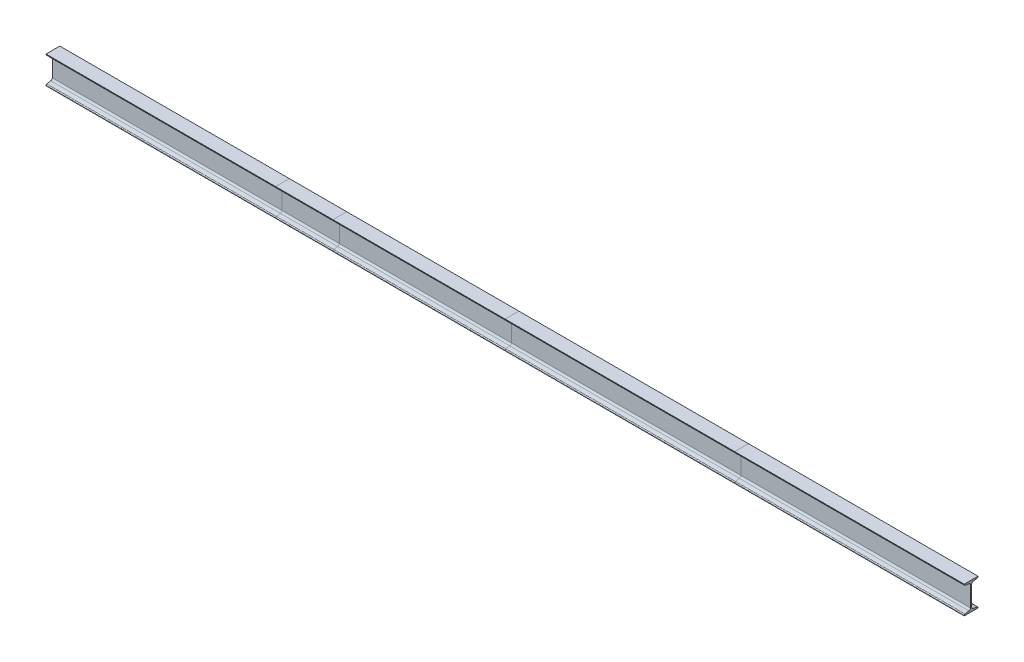
from build123d import *

# Parameters (mm, degrees)
SB_BEAM_120_X_12_1_DEPTH   = 1000
SB_BEAM_120_X_12_1_2_DEPTH = 250
SB_BEAM_120_X_12_1_3_DEPTH = 750
SB_BEAM_120_X_12_1_4_DEPTH = 1000
SB_BEAM_120_X_12_1_5_DEPTH = 1000


with BuildPart() as part:
    # Sketch11 → Sb beam 120 X 12(1) (new body)
    with BuildSketch(Plane(origin=(0, 0, 0), x_dir=(0, 0, 1), z_dir=(1, 0, 0))):
        with BuildLine():
            Line((-30, -60), (-30, -58.080070835))
            ThreePointArc((-30, -58.080070835), (-29.052095223, -55.494589303), (-26.657642624, -54.134502919))
            Line((-26.657642624, -54.134502919), (-9.184714752, -51.222135832))
            ThreePointArc((-9.184714752, -51.222135832), (-4.395809555, -48.501963064), (-2.5, -43.331))
            Line((-2.5, -43.331), (-2.5, 43.331))
            ThreePointArc((-2.5, 43.331), (-4.395809555, 48.501963064), (-9.184714752, 51.222135832))
            Line((-9.184714752, 51.222135832), (-26.657642624, 54.134502919))
            ThreePointArc((-26.657642624, 54.134502919), (-29.052095223, 55.494589303), (-30, 58.080070835))
            Line((-30, 58.080070835), (-30, 60))
            Line((-30, 60), (30, 60))
            Line((30, 60), (30, 58.080070835))
            ThreePointArc((30, 58.080070835), (29.052095223, 55.494589303), (26.657642624, 54.134502919))
            Line((26.657642624, 54.134502919), (9.184714752, 51.222135832))
            ThreePointArc((9.184714752, 51.222135832), (4.395809555, 48.501963064), (2.5, 43.331))
            Line((2.5, 43.331), (2.5, -43.331))
            ThreePointArc((2.5, -43.331), (4.395809555, -48.501963064), (9.184714752, -51.222135832))
            Line((9.184714752, -51.222135832), (26.657642624, -54.134502919))
            ThreePointArc((26.657642624, -54.134502919), (29.052095223, -55.494589303), (30, -58.080070835))
            Line((30, -58.080070835), (30, -60))
            Line((30, -60), (-30, -60))
        make_face()
    extrude(amount=SB_BEAM_120_X_12_1_DEPTH)


with BuildPart() as body_2:
    # Sketch11 on segment 2 (carried to segment 2) → Sb beam 120 X 12_1 2 (new body)
    with BuildSketch(Plane(origin=(1000, 0, 0), x_dir=(0, 0, 1), z_dir=(1, 0, 0))):
        with BuildLine():
            Line((-30, -60), (-30, -58.080070835))
            ThreePointArc((-30, -58.080070835), (-29.052095223, -55.494589303), (-26.657642624, -54.134502919))
            Line((-26.657642624, -54.134502919), (-9.184714752, -51.222135832))
            ThreePointArc((-9.184714752, -51.222135832), (-4.395809555, -48.501963064), (-2.5, -43.331))
            Line((-2.5, -43.331), (-2.5, 43.331))
            ThreePointArc((-2.5, 43.331), (-4.395809555, 48.501963064), (-9.184714752, 51.222135832))
            Line((-9.184714752, 51.222135832), (-26.657642624, 54.134502919))
            ThreePointArc((-26.657642624, 54.134502919), (-29.052095223, 55.494589303), (-30, 58.080070835))
            Line((-30, 58.080070835), (-30, 60))
            Line((-30, 60), (30, 60))
            Line((30, 60), (30, 58.080070835))
            ThreePointArc((30, 58.080070835), (29.052095223, 55.494589303), (26.657642624, 54.134502919))
            Line((26.657642624, 54.134502919), (9.184714752, 51.222135832))
            ThreePointArc((9.184714752, 51.222135832), (4.395809555, 48.501963064), (2.5, 43.331))
            Line((2.5, 43.331), (2.5, -43.331))
            ThreePointArc((2.5, -43.331), (4.395809555, -48.501963064), (9.184714752, -51.222135832))
            Line((9.184714752, -51.222135832), (26.657642624, -54.134502919))
            ThreePointArc((26.657642624, -54.134502919), (29.052095223, -55.494589303), (30, -58.080070835))
            Line((30, -58.080070835), (30, -60))
            Line((30, -60), (-30, -60))
        make_face()
    extrude(amount=SB_BEAM_120_X_12_1_2_DEPTH)


with BuildPart() as body_3:
    # Sketch11 on segment 3 (carried to segment 3) → Sb beam 120 X 12_1 3 (new body)
    with BuildSketch(Plane(origin=(1250, 0, 0), x_dir=(0, 0, 1), z_dir=(1, 0, 0))):
        with BuildLine():
            Line((-30, -60), (-30, -58.080070835))
            ThreePointArc((-30, -58.080070835), (-29.052095223, -55.494589303), (-26.657642624, -54.134502919))
            Line((-26.657642624, -54.134502919), (-9.184714752, -51.222135832))
            ThreePointArc((-9.184714752, -51.222135832), (-4.395809555, -48.501963064), (-2.5, -43.331))
            Line((-2.5, -43.331), (-2.5, 43.331))
            ThreePointArc((-2.5, 43.331), (-4.395809555, 48.501963064), (-9.184714752, 51.222135832))
            Line((-9.184714752, 51.222135832), (-26.657642624, 54.134502919))
            ThreePointArc((-26.657642624, 54.134502919), (-29.052095223, 55.494589303), (-30, 58.080070835))
            Line((-30, 58.080070835), (-30, 60))
            Line((-30, 60), (30, 60))
            Line((30, 60), (30, 58.080070835))
            ThreePointArc((30, 58.080070835), (29.052095223, 55.494589303), (26.657642624, 54.134502919))
            Line((26.657642624, 54.134502919), (9.184714752, 51.222135832))
            ThreePointArc((9.184714752, 51.222135832), (4.395809555, 48.501963064), (2.5, 43.331))
            Line((2.5, 43.331), (2.5, -43.331))
            ThreePointArc((2.5, -43.331), (4.395809555, -48.501963064), (9.184714752, -51.222135832))
            Line((9.184714752, -51.222135832), (26.657642624, -54.134502919))
            ThreePointArc((26.657642624, -54.134502919), (29.052095223, -55.494589303), (30, -58.080070835))
            Line((30, -58.080070835), (30, -60))
            Line((30, -60), (-30, -60))
        make_face()
    extrude(amount=SB_BEAM_120_X_12_1_3_DEPTH)


with BuildPart() as body_4:
    # Sketch11 on segment 4 (carried to segment 4) → Sb beam 120 X 12_1 4 (new body)
    with BuildSketch(Plane(origin=(2000, 0, 0), x_dir=(0, 0, 1), z_dir=(1, 0, 0))):
        with BuildLine():
            Line((-30, -60), (-30, -58.080070835))
            ThreePointArc((-30, -58.080070835), (-29.052095223, -55.494589303), (-26.657642624, -54.134502919))
            Line((-26.657642624, -54.134502919), (-9.184714752, -51.222135832))
            ThreePointArc((-9.184714752, -51.222135832), (-4.395809555, -48.501963064), (-2.5, -43.331))
            Line((-2.5, -43.331), (-2.5, 43.331))
            ThreePointArc((-2.5, 43.331), (-4.395809555, 48.501963064), (-9.184714752, 51.222135832))
            Line((-9.184714752, 51.222135832), (-26.657642624, 54.134502919))
            ThreePointArc((-26.657642624, 54.134502919), (-29.052095223, 55.494589303), (-30, 58.080070835))
            Line((-30, 58.080070835), (-30, 60))
            Line((-30, 60), (30, 60))
            Line((30, 60), (30, 58.080070835))
            ThreePointArc((30, 58.080070835), (29.052095223, 55.494589303), (26.657642624, 54.134502919))
            Line((26.657642624, 54.134502919), (9.184714752, 51.222135832))
            ThreePointArc((9.184714752, 51.222135832), (4.395809555, 48.501963064), (2.5, 43.331))
            Line((2.5, 43.331), (2.5, -43.331))
            ThreePointArc((2.5, -43.331), (4.395809555, -48.501963064), (9.184714752, -51.222135832))
            Line((9.184714752, -51.222135832), (26.657642624, -54.134502919))
            ThreePointArc((26.657642624, -54.134502919), (29.052095223, -55.494589303), (30, -58.080070835))
            Line((30, -58.080070835), (30, -60))
            Line((30, -60), (-30, -60))
        make_face()
    extrude(amount=SB_BEAM_120_X_12_1_4_DEPTH)


with BuildPart() as body_5:
    # Sketch11 on segment 5 (carried to segment 5) → Sb beam 120 X 12_1 5 (new body)
    with BuildSketch(Plane(origin=(3000, 0, 0), x_dir=(0, 0, 1), z_dir=(1, 0, 0))):
        with BuildLine():
            Line((-30, -60), (-30, -58.080070835))
            ThreePointArc((-30, -58.080070835), (-29.052095223, -55.494589303), (-26.657642624, -54.134502919))
            Line((-26.657642624, -54.134502919), (-9.184714752, -51.222135832))
            ThreePointArc((-9.184714752, -51.222135832), (-4.395809555, -48.501963064), (-2.5, -43.331))
            Line((-2.5, -43.331), (-2.5, 43.331))
            ThreePointArc((-2.5, 43.331), (-4.395809555, 48.501963064), (-9.184714752, 51.222135832))
            Line((-9.184714752, 51.222135832), (-26.657642624, 54.134502919))
            ThreePointArc((-26.657642624, 54.134502919), (-29.052095223, 55.494589303), (-30, 58.080070835))
            Line((-30, 58.080070835), (-30, 60))
            Line((-30, 60), (30, 60))
            Line((30, 60), (30, 58.080070835))
            ThreePointArc((30, 58.080070835), (29.052095223, 55.494589303), (26.657642624, 54.134502919))
            Line((26.657642624, 54.134502919), (9.184714752, 51.222135832))
            ThreePointArc((9.184714752, 51.222135832), (4.395809555, 48.501963064), (2.5, 43.331))
            Line((2.5, 43.331), (2.5, -43.331))
            ThreePointArc((2.5, -43.331), (4.395809555, -48.501963064), (9.184714752, -51.222135832))
            Line((9.184714752, -51.222135832), (26.657642624, -54.134502919))
            ThreePointArc((26.657642624, -54.134502919), (29.052095223, -55.494589303), (30, -58.080070835))
            Line((30, -58.080070835), (30, -60))
            Line((30, -60), (-30, -60))
        make_face()
    extrude(amount=SB_BEAM_120_X_12_1_5_DEPTH)


solid = Compound([part.part, body_2.part, body_3.part, body_4.part, body_5.part])
